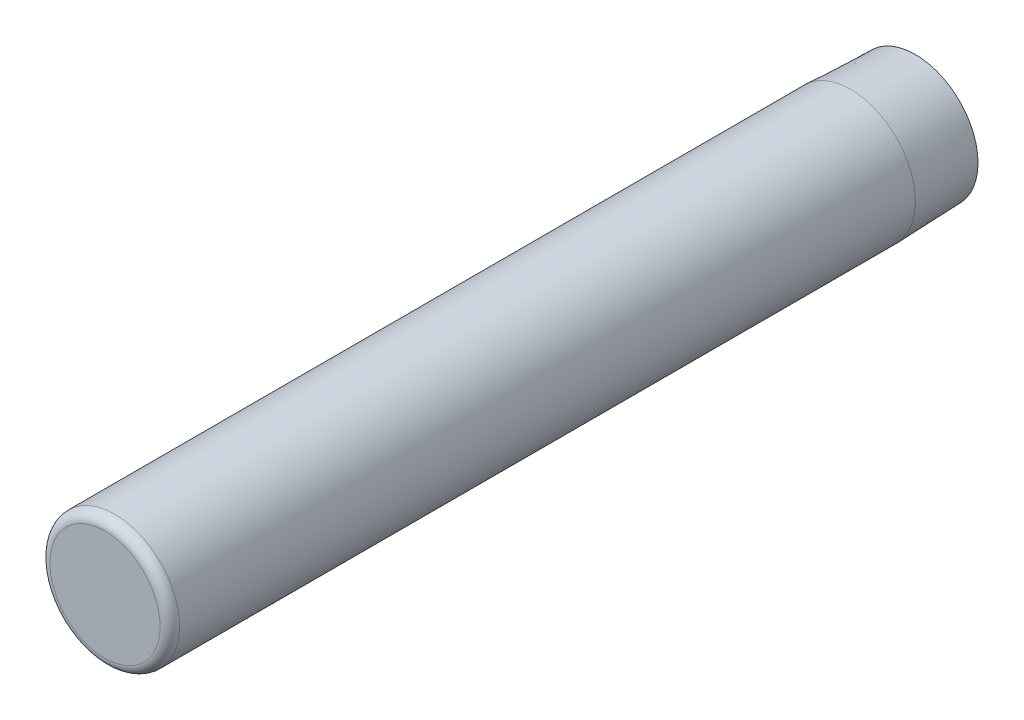
from build123d import *

# Parameters (mm, degrees)
CROQUIS1_R              = 2
SALIENTE_EXTRUIR1_DEPTH = 25
CHAFL_N1_SIZE           = 2
CHAFL_N1_SIZE2          = 0.069841539
REDONDEO1_R             = 0.3


with BuildPart() as part:
    # Croquis1 → Saliente-Extruir1 (new body)
    with BuildSketch(Plane.XY):
        Circle(CROQUIS1_R)
    extrude(amount=SALIENTE_EXTRUIR1_DEPTH)

    # Chaflán1
    chafl_n1_edges = [part.edges().sort_by_distance(p)[0] for p in [
        (-2, 0, 0),
    ]]
    chafl_n1_side = [part.faces().sort_by_distance(p)[0] for p in [
        (-2, 0, 12.5),
    ]]
    chamfer(chafl_n1_edges, length=CHAFL_N1_SIZE, length2=CHAFL_N1_SIZE2, reference=chafl_n1_side[0])

    # Redondeo1
    redondeo1_edges = [part.edges().sort_by_distance(p)[0] for p in [
        (-2, 0, 25),
    ]]
    fillet(redondeo1_edges, radius=REDONDEO1_R)


solid = part.part
